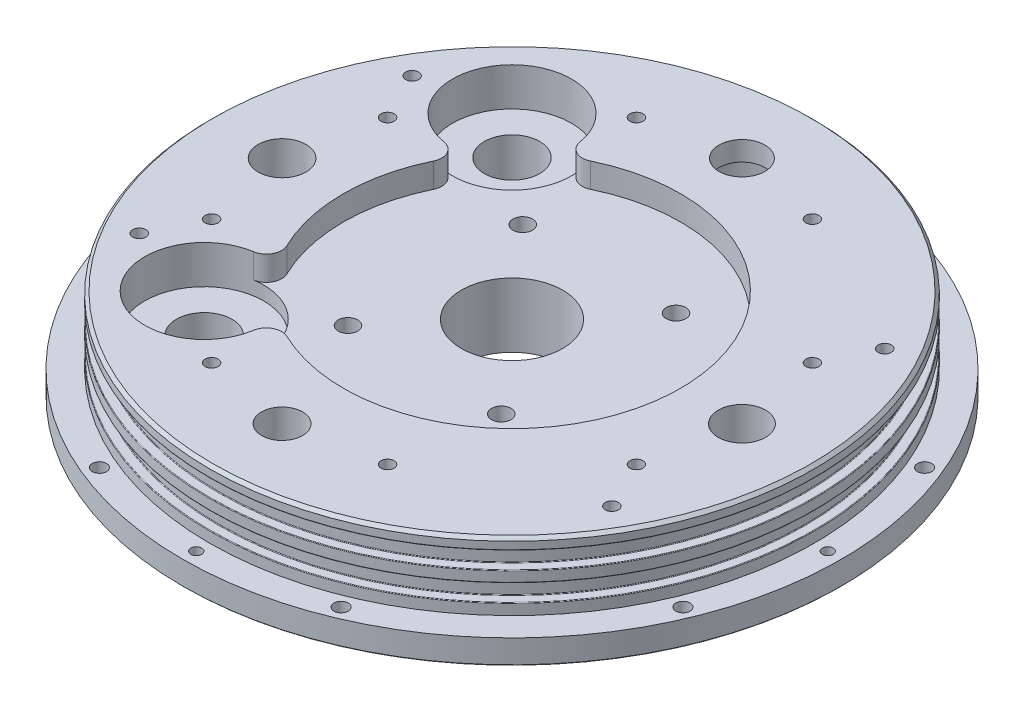
from build123d import *

# Parameters (mm, degrees)
SKETCH1_R                   = 68.2625
BOSS_EXTRUDE1_DEPTH         = 19.05
SKETCH2_R                   = 11.65
CUT_EXTRUDE1_DEPTH          = 1.5
M22X1_0_TAPPED_HOLE2_D      = 20.65
M22X1_0_TAPPED_HOLE2_DEPTH  = 3.50012
SKETCH5_R                   = 10.325
CUT_EXTRUDE2_DEPTH          = 1.4
SKETCH6_R                   = 9.65
CUT_EXTRUDE3_DEPTH          = 0.9
SKETCH7_R                   = 10.1
CUT_EXTRUDE4_DEPTH          = 1.2
SKETCH8_R                   = 9.515
CUT_EXTRUDE5_DEPTH          = 5
CHAMFER1_SIZE               = 0.434643369
CHAMFER1_SIZE2              = 0.5
SKETCH9_R                   = 7.5
CUT_EXTRUDE6_DEPTH          = 1.5
SKETCH10_W                  = 13.97
SKETCH10_H                  = 5.715
F_4_CLEARANCE_HOLE1_D       = 2.9464
F_4_40_TAPPED_HOLE1_D       = 2.2606
HOLE2_D                     = 9.5
M10X1_5_TAPPED_HOLE2_D      = 8.5
M10X1_5_TAPPED_HOLE2_DEPTH  = 19.05
HOLE4_D                     = 9.8
F_7_8_20_TAPPED_HOLE1_D     = 20.9804
F_7_8_20_TAPPED_HOLE1_DEPTH = 19.05
F_7_16_20_TAPPED_HOLE1_D    = 9.92124
F_7_16_CLEARANCE_HOLE1_D    = 11.510000094
SKETCH31_R                  = 12.319
CUT_EXTRUDE7_DEPTH          = 7.9375
SKETCH32_R                  = 7.1374
SKETCH32_R_2                = 4.7625
CUT_EXTRUDE8_DEPTH          = 7.62
SKETCH33_R                  = 13.6525
SKETCH33_R_2                = 6.35
SKETCH33_R_3                = 11.1125
SKETCH33_R_4                = 2.54
SKETCH33_R_5                = 10.4775
SKETCH33_R_6                = 5.08
SKETCH33_R_7                = 15.24
SKETCH33_R_8                = 4.7625
SKETCH33_R_9                = 24.4475
SKETCH33_R_10               = 5.73405
CUT_EXTRUDE9_DEPTH          = 0.635
CHAMFER2_SIZE               = 0.434643369
CHAMFER2_SIZE2              = 0.5
CHAMFER3_SIZE               = 0.635
CHAMFER3_SIZE2              = 0.170147737
SKETCH34_R                  = 0.8509
CUT_EXTRUDE10_DEPTH         = 3.365
SKETCH38_W                  = 3.556
SKETCH38_H                  = 2.032
SKETCH39_W                  = 3.556
SKETCH39_H                  = 2.032
FILLET2_R                   = 0.127
CHAMFER4_SIZE               = 0.254
F_6_32_TAPPED_HOLE2_D       = 2.7051
F_6_32_TAPPED_HOLE2_DEPTH   = 9.99744
F_6_32_TAPPED_HOLE2_TIP     = 0.81269403
SKETCH43_R                  = 34.925
CUT_EXTRUDE13_DEPTH         = 5.08
F_6_32_TAPPED_HOLE1_D       = 2.7051
F_6_32_TAPPED_HOLE1_DEPTH   = 9.18474597
F_6_32_TAPPED_HOLE1_TIP     = 0.81269403
F_10_32_TAPPED_HOLE1_D      = 4.0386
F_10_32_TAPPED_HOLE1_DEPTH  = 9.525
F_10_32_TAPPED_HOLE1_TIP    = 1.213317848
FILLET4_R                   = 3.175
CHAMFER5_SIZE               = 0.635


with BuildPart() as part:
    # Sketch1 → Boss-Extrude1 (new body)
    with BuildSketch(Plane.XZ.offset(5.08)):
        Circle(SKETCH1_R)
    extrude(amount=-BOSS_EXTRUDE1_DEPTH)

    # Sketch2 → Cut-Extrude1 (cut)
    with BuildSketch(Plane.XZ.offset(5.08)):
        with Locations((0, -47.625)):
            Circle(SKETCH2_R)
    extrude(amount=-CUT_EXTRUDE1_DEPTH, mode=Mode.SUBTRACT)

    # M22x1.0 Tapped Hole2
    with Locations(Plane(origin=(0, -3.58, 0), x_dir=(-1, 0, 0), z_dir=(0, -1, 0))):
        with Locations((0, 47.625)):
            Hole(M22X1_0_TAPPED_HOLE2_D / 2, depth=M22X1_0_TAPPED_HOLE2_DEPTH)

    # Sketch5 → Cut-Extrude2 (cut)
    with BuildSketch(Plane.XZ.offset(0.07988)):
        with Locations((0, -47.625)):
            Circle(SKETCH5_R)
    extrude(amount=-CUT_EXTRUDE2_DEPTH, mode=Mode.SUBTRACT)

    # Sketch6 → Cut-Extrude3 (cut)
    with BuildSketch(Plane.XZ.offset(-1.32012)):
        with Locations((0, -47.625)):
            Circle(SKETCH6_R)
    extrude(amount=-CUT_EXTRUDE3_DEPTH, mode=Mode.SUBTRACT)

    # Sketch7 → Cut-Extrude4 (cut)
    with BuildSketch(Plane.XZ.offset(-2.22)):
        with Locations((0, -47.625)):
            Circle(SKETCH7_R)
    extrude(amount=-CUT_EXTRUDE4_DEPTH, mode=Mode.SUBTRACT)

    # Sketch8 → Cut-Extrude5 (cut)
    with BuildSketch(Plane.XZ.offset(-3.42)):
        with Locations((0, -47.625)):
            Circle(SKETCH8_R)
    extrude(amount=-CUT_EXTRUDE5_DEPTH, mode=Mode.SUBTRACT)

    # Chamfer1
    chamfer1_edges = [part.edges().sort_by_distance(p)[0] for p in [
        (-9.515, 3.42, -47.625),
    ]]
    chamfer1_side = [part.faces().sort_by_distance(p)[0] for p in [
        (-9.81432886, 3.42, -47.625),
    ]]
    chamfer(chamfer1_edges, length=CHAMFER1_SIZE, length2=CHAMFER1_SIZE2, reference=chamfer1_side[0])

    # Sketch9 → Cut-Extrude6 (cut)
    with BuildSketch(Plane.XZ.offset(-8.42)):
        with Locations((0, -47.625)):
            Circle(SKETCH9_R)
    extrude(amount=-CUT_EXTRUDE6_DEPTH, mode=Mode.SUBTRACT)

    # Sketch10 → Cut-Revolve1 (revolve, cut)
    with BuildSketch(Plane(origin=(0, 0, 0), x_dir=(0, -1, 0), z_dir=(-0.707106781, 0, 0.707106781))):
        with Locations((-6.985, 65.4558)):
            Rectangle(SKETCH10_W, SKETCH10_H)
    revolve(axis=Axis((0, 0, 0), (0, 1, 0)), mode=Mode.SUBTRACT)

    # #4 Clearance Hole1 (through all)
    with Locations(Plane(origin=(0, -5.08, 0), x_dir=(-1, 0, 0), z_dir=(0, -1, 0))):
        with Locations((25.029409894, -60.426340824), (25.029409894, 60.426340824), (60.426340824, -25.029409894), (-25.029409894, 60.426340824), (-60.426340824, 25.029409894), (-60.426340824, -25.029409894), (-25.029409894, -60.426340824), (60.426340824, 25.029409894)):
            Hole(F_4_CLEARANCE_HOLE1_D / 2)

    # #4-40 Tapped Hole1 (through all)
    with Locations(Plane(origin=(0, -5.08, 0), x_dir=(-1, 0, 0), z_dir=(0, -1, 0))):
        with Locations((0, -65.405), (0, 65.405), (-65.405, 0), (65.405, 0)):
            Hole(F_4_40_TAPPED_HOLE1_D / 2)

    # Hole2 (through all)
    with Locations(Plane(origin=(0, 9.92, 0), x_dir=(-1, 0, 0), z_dir=(0, -1, 0))):
        with Locations((0, 47.625)):
            Hole(HOLE2_D / 2)

    # M10x1.5 Tapped Hole2
    with Locations(Plane(origin=(0, -5.08, 0), x_dir=(-1, 0, 0), z_dir=(0, -1, 0))):
        with Locations((0, -47.625)):
            Hole(M10X1_5_TAPPED_HOLE2_D / 2, depth=M10X1_5_TAPPED_HOLE2_DEPTH)

    # Hole4 (through all)
    with Locations(Plane(origin=(0, -5.08, 0), x_dir=(-1, 0, 0), z_dir=(0, -1, 0))):
        with Locations((-47.625, 0)):
            Hole(HOLE4_D / 2)

    # 7/8-20 Tapped Hole1
    with Locations(Plane(origin=(0, -5.08, 0), x_dir=(-1, 0, 0), z_dir=(0, -1, 0))):
        with Locations((0, 0)):
            Hole(F_7_8_20_TAPPED_HOLE1_D / 2, depth=F_7_8_20_TAPPED_HOLE1_DEPTH)

    # 7/16-20 Tapped Hole1 (through all)
    with Locations(Plane(origin=(0, -5.08, 0), x_dir=(-1, 0, 0), z_dir=(0, -1, 0))):
        with Locations((47.625, 0)):
            Hole(F_7_16_20_TAPPED_HOLE1_D / 2)

    # 7/16 Clearance Hole1 (through all)
    with Locations(Plane(origin=(0, 13.97, 0), x_dir=(1, 0, 0), z_dir=(0, 1, 0))):
        with Locations((-31.87990923, 31.87990923), (-31.87990923, -31.87990923)):
            Hole(F_7_16_CLEARANCE_HOLE1_D / 2)

    # Sketch31 → Cut-Extrude7 (cut)
    with BuildSketch(Plane(origin=(0, 13.97, 0), x_dir=(-1, 0, 0), z_dir=(0, 1, 0))):
        with Locations((31.87990923, -31.87990923)):
            Circle(SKETCH31_R)
        with Locations((31.87990923, 31.87990923)):
            Circle(SKETCH31_R)
    extrude(amount=-CUT_EXTRUDE7_DEPTH, mode=Mode.SUBTRACT)

    # Sketch32 → Cut-Extrude8 (cut)
    with BuildSketch(Plane.XZ.offset(5.08)):
        with Locations((47.625, 0)):
            Circle(SKETCH32_R)
        with Locations((47.625, 0)):
            Circle(SKETCH32_R_2, mode=Mode.SUBTRACT)
    extrude(amount=-CUT_EXTRUDE8_DEPTH, mode=Mode.SUBTRACT)

    # Sketch33 → Cut-Extrude9 (cut)
    with BuildSketch(Plane.XZ.offset(5.08)):
        with Locations((47.625, 0)):
            Circle(SKETCH33_R)
        with Locations((47.625, 0)):
            Circle(SKETCH33_R_2, mode=Mode.SUBTRACT)
        with Locations((0, 47.625)):
            Circle(SKETCH33_R_3)
        with Locations((0, 47.625)):
            Circle(SKETCH33_R_4, mode=Mode.SUBTRACT)
        with Locations((-31.87990923, -31.87990923)):
            Circle(SKETCH33_R_5)
        with Locations((-31.87990923, -31.87990923)):
            Circle(SKETCH33_R_6, mode=Mode.SUBTRACT)
        with Locations((-47.625, 0)):
            Circle(SKETCH33_R_7)
        with Locations((-47.625, 0)):
            Circle(SKETCH33_R_8, mode=Mode.SUBTRACT)
        with Locations((-31.87990923, 31.87990923)):
            Circle(SKETCH33_R_5)
        with Locations((-31.87990923, 31.87990923)):
            Circle(SKETCH33_R_6, mode=Mode.SUBTRACT)
        Circle(SKETCH33_R_9)
        Circle(SKETCH33_R_10, mode=Mode.SUBTRACT)
    extrude(amount=-CUT_EXTRUDE9_DEPTH, mode=Mode.SUBTRACT)

    # Chamfer2
    chamfer2_edges = [part.edges().sort_by_distance(p)[0] for p in [
        (-9.65, 1.32012, -47.625),
    ]]
    chamfer2_side = [part.faces().sort_by_distance(p)[0] for p in [
        (-10.032964899, 1.32012, -47.625),
    ]]
    chamfer(chamfer2_edges, length=CHAMFER2_SIZE, length2=CHAMFER2_SIZE2, reference=chamfer2_side[0])

    # Chamfer3
    chamfer3_edges = [part.edges().sort_by_distance(p)[0] for p in [
        (40.4876, -4.445, 0),
    ]]
    chamfer3_side = [part.faces().sort_by_distance(p)[0] for p in [
        (40.4876, -0.9525, 0),
    ]]
    chamfer(chamfer3_edges, length=CHAMFER3_SIZE, length2=CHAMFER3_SIZE2, reference=chamfer3_side[0])

    # Sketch34 → Cut-Extrude10 (cut)
    with BuildSketch(Plane.XZ.offset(4.445)):
        with Locations((59.625, 0)):
            Circle(SKETCH34_R)
    extrude(amount=-CUT_EXTRUDE10_DEPTH, mode=Mode.SUBTRACT)

    # Sketch38 → Cut-Revolve4 (revolve, cut)
    with BuildSketch(Plane(origin=(0, 0, 0), x_dir=(0, 1, 0), z_dir=(0.707106781, 0, -0.707106781))):
        with Locations((9.906, 61.6585)):
            Rectangle(SKETCH38_W, SKETCH38_H)
    revolve(axis=Axis((0, 8.128, 0), (0, 1, 0)), mode=Mode.SUBTRACT)

    # Sketch39 → Cut-Revolve5 (revolve, cut)
    with BuildSketch(Plane(origin=(0, 0, 0), x_dir=(0, -1, 0), z_dir=(-0.707106781, 0, 0.707106781))):
        with Locations((-4.064, 61.6585)):
            Rectangle(SKETCH39_W, SKETCH39_H)
    revolve(axis=Axis((0, 2.286, 0), (0, 1, 0)), mode=Mode.SUBTRACT)

    # Fillet2
    fillet2_edges = [part.edges().sort_by_distance(p)[0] for p in [
        (-44.263682421, 11.684, -44.263682421),
        (-44.263682421, 8.128, -44.263682421),
        (-42.880722978, 8.128, -42.880722978),
        (-42.880722978, 11.684, -42.880722978),
        (-44.263682421, 2.286, -44.263682421),
        (-42.880722978, 2.286, -42.880722978),
        (-44.263682421, 5.842, -44.263682421),
        (-42.880722978, 5.842, -42.880722978),
    ]]
    fillet(fillet2_edges, radius=FILLET2_R)

    # Chamfer4
    chamfer4_edges = [part.edges().sort_by_distance(p)[0] for p in [
        (-68.2625, -5.08, 0),
    ]]
    chamfer(chamfer4_edges, length=CHAMFER4_SIZE)

    # #6-32 Tapped Hole2
    with Locations(Plane(origin=(0, 13.97, 0), x_dir=(1, 0, 0), z_dir=(0, 1, 0))):
        with Locations((-48.943425695, 28.2575), (-48.943425695, -28.2575), (48.943425695, -28.2575), (48.943425695, 28.2575)):
            Hole(F_6_32_TAPPED_HOLE2_D / 2, depth=F_6_32_TAPPED_HOLE2_DEPTH)
            with Locations((0, 0, -(F_6_32_TAPPED_HOLE2_DEPTH + F_6_32_TAPPED_HOLE2_TIP / 2))):  # 118° drill point
                Cone(0, F_6_32_TAPPED_HOLE2_D / 2, F_6_32_TAPPED_HOLE2_TIP, mode=Mode.SUBTRACT)

    # Sketch43 → Cut-Extrude13 (cut)
    with BuildSketch(Plane(origin=(0, 13.97, 0), x_dir=(1, 0, 0), z_dir=(0, 1, 0))):
        Circle(SKETCH43_R)
    extrude(amount=-CUT_EXTRUDE13_DEPTH, mode=Mode.SUBTRACT)

    # #6-32 Tapped Hole1
    with Locations(Plane(origin=(0, 13.97, 0), x_dir=(1, 0, 0), z_dir=(0, 1, 0))):
        with Locations((18.225298466, -43.999762736), (43.999762736, 18.225298466), (-43.999762736, 18.225298466), (18.225298466, 43.999762736), (-18.225298466, 43.999762736), (-18.225298466, -43.999762736), (-43.999762736, -18.225298466), (43.999762736, -18.225298466)):
            Hole(F_6_32_TAPPED_HOLE1_D / 2, depth=F_6_32_TAPPED_HOLE1_DEPTH)
            with Locations((0, 0, -(F_6_32_TAPPED_HOLE1_DEPTH + F_6_32_TAPPED_HOLE1_TIP / 2))):  # 118° drill point
                Cone(0, F_6_32_TAPPED_HOLE1_D / 2, F_6_32_TAPPED_HOLE1_TIP, mode=Mode.SUBTRACT)

    # #10-32 Tapped Hole1
    with Locations(Plane(origin=(0, 8.89, 0), x_dir=(1, 0, 0), z_dir=(0, 1, 0))):
        with Locations((15.875, 18.0975), (-15.875, -18.0975), (-15.875, 18.0975), (15.875, -18.0975)):
            Hole(F_10_32_TAPPED_HOLE1_D / 2, depth=F_10_32_TAPPED_HOLE1_DEPTH)
            with Locations((0, 0, -(F_10_32_TAPPED_HOLE1_DEPTH + F_10_32_TAPPED_HOLE1_TIP / 2))):  # 118° drill point
                Cone(0, F_10_32_TAPPED_HOLE1_D / 2, F_10_32_TAPPED_HOLE1_TIP, mode=Mode.SUBTRACT)

    # Fillet4
    fillet4_edges = [part.edges().sort_by_distance(p)[0] for p in [
        (-28.634009894, 11.43, -19.996227203),
        (-19.996227203, 11.43, -28.634009894),
        (-19.996227203, 11.43, 28.634009894),
        (-28.634009894, 11.43, 19.996227203),
    ]]
    fillet(fillet4_edges, radius=FILLET4_R)

    # Chamfer5
    chamfer5_edges = [part.edges().sort_by_distance(p)[0] for p in [
        (-44.263682421, 13.97, -44.263682421),
    ]]
    chamfer(chamfer5_edges, length=CHAMFER5_SIZE)


solid = part.part
